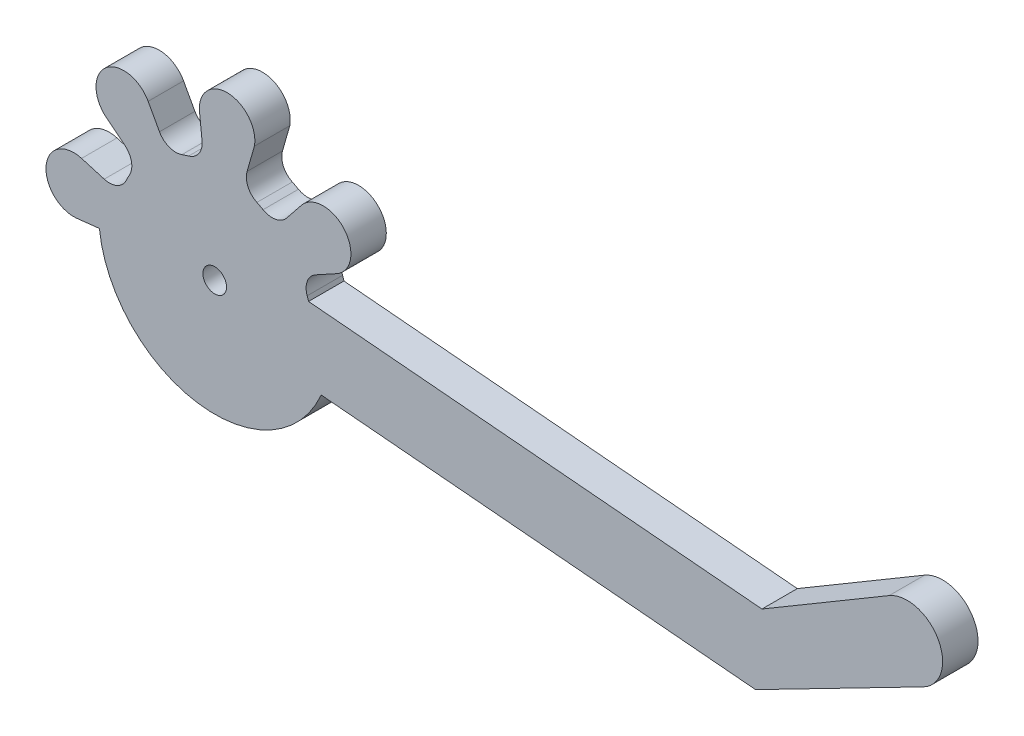
from build123d import *

# Parameters (mm, degrees)
MODEL_R                 = 1
SALIENTE_EXTRUIR1_DEPTH = 3


with BuildPart() as part:
    # Model → Saliente-Extruir1 (new body)
    with BuildSketch(Plane.XY):
        with BuildLine():
            Line((17.861622063, 18.20706488), (56.277425925, 14.846117598))
            Line((56.277425925, 14.846117598), (67.057874252, 21.223257456))
            ThreePointArc((67.057874252, 21.223257456), (71.209474737, 20.095027087), (69.964368376, 15.976969231))
            Line((69.964368376, 15.976969231), (55.736188762, 8.659748523))
            Line((55.736188762, 8.659748523), (18.934882774, 11.8794456))
            ThreePointArc((18.934882774, 11.8794456), (8.451096418, 6.06231898), (0.138961898, 14.702756365))
            Line((0.138961898, 14.702756365), (-1.772059081, 14.490982222))
            ThreePointArc((-1.772059081, 14.490982222), (-1.880981546, 14.481466547), (-1.990228383, 14.477019049))
            ThreePointArc((-1.990228383, 14.477019049), (-2.005285406, 14.476804272), (-2.020343495, 14.476685822))
            ThreePointArc((-2.020343495, 14.476685822), (-4.376324998, 17.035772608), (-1.611755391, 19.146869222))
            ThreePointArc((-1.611755391, 19.146869222), (-1.596946637, 19.144137761), (-1.582155659, 19.141311623))
            ThreePointArc((-1.582155659, 19.141311623), (-1.475340827, 19.117961178), (-1.369725519, 19.08967588))
            Line((-1.369725519, 19.08967588), (0.550429384, 18.527326068))
            ThreePointArc((0.550429384, 18.527326068), (1.632460158, 18.600931479), (2.408362946, 19.35868026))
            ThreePointArc((2.408362946, 19.35868026), (2.540100184, 19.623117729), (2.6811533, 19.882705658))
            ThreePointArc((2.6811533, 19.882705658), (2.856825208, 20.952914859), (2.296491875, 21.881480908))
            Line((2.296491875, 21.881480908), (0.734486272, 23.131829117))
            ThreePointArc((0.734486272, 23.131829117), (0.65073786, 23.202120333), (0.570343825, 23.276224656))
            ThreePointArc((0.570343825, 23.276224656), (0.559545032, 23.286719709), (0.548813598, 23.297283629))
            ThreePointArc((0.548813598, 23.297283629), (0.692430721, 26.772761747), (4.140047368, 26.310686561))
            ThreePointArc((4.140047368, 26.310686561), (4.148587304, 26.298283756), (4.157047724, 26.285826574))
            ThreePointArc((4.157047724, 26.285826574), (4.216065957, 26.193785825), (4.270746533, 26.099103798))
            Line((4.270746533, 26.099103798), (5.230859716, 24.343707882))
            ThreePointArc((5.230859716, 24.343707882), (6.048017899, 23.630643468), (7.132473325, 23.617806645))
            ThreePointArc((7.132473325, 23.617806645), (7.412611146, 23.711639877), (7.695907146, 23.795456646))
            ThreePointArc((7.695907146, 23.795456646), (8.576878126, 24.427990033), (8.837257977, 25.480800883))
            Line((8.837257977, 25.480800883), (8.602586519, 27.717719751))
            ThreePointArc((8.602586519, 27.717719751), (11.161673306, 30.073701254), (13.272769919, 27.309131647))
            Line((13.272769919, 27.309131647), (12.653226766, 25.146946875))
            ThreePointArc((12.653226766, 25.146946875), (12.726832176, 24.064916101), (13.484580957, 23.289013313))
            Line((13.484580957, 23.289013313), (14.008606355, 23.016222959))
            ThreePointArc((14.008606355, 23.016222959), (15.078815556, 22.840551052), (16.007381606, 23.400884385))
            Line((16.007381606, 23.400884385), (17.257729815, 24.962889987))
            ThreePointArc((17.257729815, 24.962889987), (17.328021031, 25.046638399), (17.402125353, 25.127032434))
            ThreePointArc((17.402125353, 25.127032434), (17.412620407, 25.137831227), (17.423184327, 25.148562661))
            ThreePointArc((17.423184327, 25.148562661), (20.898662444, 25.004945538), (20.436587259, 21.557328891))
            ThreePointArc((20.436587259, 21.557328891), (20.424184454, 21.548788955), (20.411727272, 21.540328535))
            ThreePointArc((20.411727272, 21.540328535), (20.319686522, 21.481310302), (20.225004495, 21.426629727))
            Line((20.225004495, 21.426629727), (18.46960858, 20.466516543))
            ThreePointArc((18.46960858, 20.466516543), (17.756544167, 19.64935836), (17.743707345, 18.564902935))
            ThreePointArc((17.743707345, 18.564902935), (17.804692888, 18.386652235), (17.861622063, 18.20706488))
        make_face()
        with Locations((9.911638477, 15.785737779)):
            Circle(MODEL_R, mode=Mode.SUBTRACT)
    extrude(amount=SALIENTE_EXTRUIR1_DEPTH)


solid = part.part
